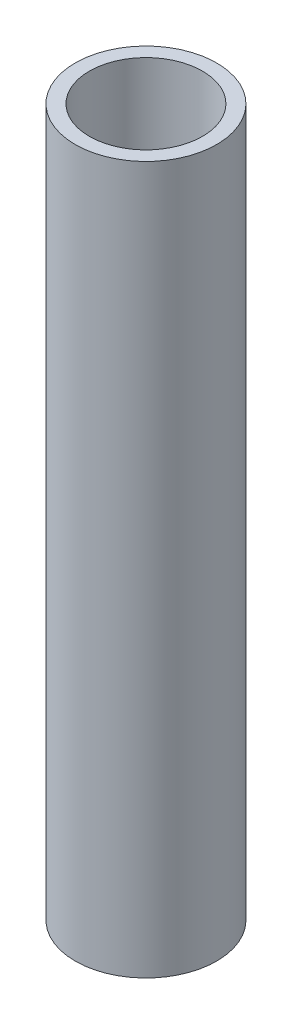
from build123d import *

# Parameters (mm, degrees)
SKETCH1_R           = 10
SKETCH1_R_2         = 8
BOSS_EXTRUDE1_DEPTH = 100


with BuildPart() as part:
    # Sketch1 → Boss-Extrude1 (new body)
    with BuildSketch(Plane(origin=(0, 0, 0), x_dir=(1, 0, 0), z_dir=(0, 1, 0))):
        Circle(SKETCH1_R)
        Circle(SKETCH1_R_2, mode=Mode.SUBTRACT)
    extrude(amount=BOSS_EXTRUDE1_DEPTH)


solid = part.part
